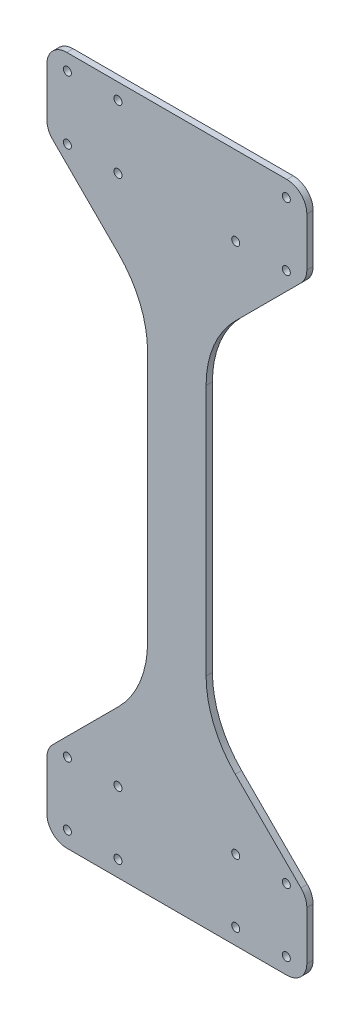
from build123d import *

# Parameters (mm, degrees)
BOSS_EXTRUDE1_DEPTH = 3.175
CUT_EXTRUDE1_DEPTH  = 10
SKETCH3_R           = 2.0193
BOSS_EXTRUDE2_DEPTH = 3.175
FILLET1_R           = 10
FILLET2_R           = 50


with BuildPart() as part:
    # Sketch1 → Boss-Extrude1 (new body)
    with BuildSketch(Plane.XY):
        Polygon((165.934536959, -16.66935), (157.315236959, -8.05005), (115.359952094, -8.05005), (89.959952094, -8.05005), (48.004667228, -8.05005), (39.385367228, -16.66935), (39.385367228, -40.05005), (39.385367228, -52.41105), (165.934536959, -56.67505), (165.934536959, -42.05005), align=None)
        with BuildLine():
            ThreePointArc((47.685367228, -44.38075), (49.704667228, -46.40005), (47.685367228, -48.41935))
            ThreePointArc((47.685367228, -48.41935), (45.666067228, -46.40005), (47.685367228, -44.38075))
        make_face(mode=Mode.SUBTRACT)
        with BuildLine():
            ThreePointArc((47.685367228, -12.63075), (49.704667228, -14.65005), (47.685367228, -16.66935))
            ThreePointArc((47.685367228, -16.66935), (45.666067228, -14.65005), (47.685367228, -12.63075))
        make_face(mode=Mode.SUBTRACT)
        with BuildLine():
            ThreePointArc((73.085367228, -44.38075), (75.104667228, -46.40005), (73.085367228, -48.41935))
            ThreePointArc((73.085367228, -48.41935), (71.066067228, -46.40005), (73.085367228, -44.38075))
        make_face(mode=Mode.SUBTRACT)
        with BuildLine():
            ThreePointArc((73.085367228, -12.63075), (75.104667228, -14.65005), (73.085367228, -16.66935))
            ThreePointArc((73.085367228, -16.66935), (71.066067228, -14.65005), (73.085367228, -12.63075))
        make_face(mode=Mode.SUBTRACT)
        with BuildLine():
            ThreePointArc((132.234536959, -44.38075), (134.253836959, -46.40005), (132.234536959, -48.41935))
            ThreePointArc((132.234536959, -48.41935), (130.215236959, -46.40005), (132.234536959, -44.38075))
        make_face(mode=Mode.SUBTRACT)
        with BuildLine():
            ThreePointArc((132.234536959, -12.63075), (134.253836959, -14.65005), (132.234536959, -16.66935))
            ThreePointArc((132.234536959, -16.66935), (130.215236959, -14.65005), (132.234536959, -12.63075))
        make_face(mode=Mode.SUBTRACT)
        with BuildLine():
            ThreePointArc((157.634536959, -44.38075), (159.653836959, -46.40005), (157.634536959, -48.41935))
            ThreePointArc((157.634536959, -48.41935), (155.615236959, -46.40005), (157.634536959, -44.38075))
        make_face(mode=Mode.SUBTRACT)
        with BuildLine():
            ThreePointArc((157.634536959, -12.63075), (159.653836959, -14.65005), (157.634536959, -16.66935))
            ThreePointArc((157.634536959, -16.66935), (155.615236959, -14.65005), (157.634536959, -12.63075))
        make_face(mode=Mode.SUBTRACT)
        Polygon((115.359952094, -8.05005), (157.315236959, -8.05005), (115.359952094, 33.905234866), align=None)
        Polygon((89.959952094, -8.05005), (115.359952094, -8.05005), (115.359952094, 33.905234866), (115.359952094, 203.394265134), (115.359952094, 245.34955), (89.959952094, 245.34955), (89.959952094, 203.394265134), (89.959952094, 33.905234866), align=None)
        Polygon((48.004667228, -8.05005), (89.959952094, -8.05005), (89.959952094, 33.905234866), align=None)
        Polygon((89.959952094, 245.34955), (115.359952094, 245.34955), (157.315236959, 245.34955), (165.934536959, 253.96885), (165.934536959, 279.34955), (165.934536959, 293.97455), (39.385367228, 289.71055), (39.385367228, 277.34955), (39.385367228, 253.96885), (48.004667228, 245.34955), align=None)
        with BuildLine():
            ThreePointArc((47.685367228, 253.96885), (49.704667228, 251.94955), (47.685367228, 249.93025))
            ThreePointArc((47.685367228, 249.93025), (45.666067228, 251.94955), (47.685367228, 253.96885))
        make_face(mode=Mode.SUBTRACT)
        with BuildLine():
            ThreePointArc((47.685367228, 285.71885), (49.704667228, 283.69955), (47.685367228, 281.68025))
            ThreePointArc((47.685367228, 281.68025), (45.666067228, 283.69955), (47.685367228, 285.71885))
        make_face(mode=Mode.SUBTRACT)
        with BuildLine():
            ThreePointArc((73.085367228, 253.96885), (75.104667228, 251.94955), (73.085367228, 249.93025))
            ThreePointArc((73.085367228, 249.93025), (71.066067228, 251.94955), (73.085367228, 253.96885))
        make_face(mode=Mode.SUBTRACT)
        with BuildLine():
            ThreePointArc((73.085367228, 285.71885), (75.104667228, 283.69955), (73.085367228, 281.68025))
            ThreePointArc((73.085367228, 281.68025), (71.066067228, 283.69955), (73.085367228, 285.71885))
        make_face(mode=Mode.SUBTRACT)
        with BuildLine():
            ThreePointArc((132.234536959, 253.96885), (134.253836959, 251.94955), (132.234536959, 249.93025))
            ThreePointArc((132.234536959, 249.93025), (130.215236959, 251.94955), (132.234536959, 253.96885))
        make_face(mode=Mode.SUBTRACT)
        with BuildLine():
            ThreePointArc((157.634536959, 253.96885), (159.653836959, 251.94955), (157.634536959, 249.93025))
            ThreePointArc((157.634536959, 249.93025), (155.615236959, 251.94955), (157.634536959, 253.96885))
        make_face(mode=Mode.SUBTRACT)
        with BuildLine():
            ThreePointArc((157.634536959, 285.71885), (159.653836959, 283.69955), (157.634536959, 281.68025))
            ThreePointArc((157.634536959, 281.68025), (155.615236959, 283.69955), (157.634536959, 285.71885))
        make_face(mode=Mode.SUBTRACT)
        Polygon((115.359952094, 245.34955), (115.359952094, 203.394265134), (157.315236959, 245.34955), align=None)
        Polygon((48.004667228, 245.34955), (89.959952094, 203.394265134), (89.959952094, 245.34955), align=None)
    extrude(amount=BOSS_EXTRUDE1_DEPTH)

    # Sketch2 → Cut-Extrude1 (cut)
    with BuildSketch(Plane.XY.offset(3.175)):
        Polygon((84.385367228, -52.41105), (39.385367228, -52.41105), (165.934536959, -56.67505), (165.934536959, -52.41105), (120.934536959, -52.41105), align=None)
        Polygon((120.934536959, 289.71055), (165.934536959, 289.71055), (165.934536959, 293.97455), (39.385367228, 289.71055), (84.385367228, 289.71055), align=None)
    extrude(amount=-CUT_EXTRUDE1_DEPTH, mode=Mode.SUBTRACT)

    # Sketch3 → Boss-Extrude2 (add)
    with BuildSketch(Plane.XY.offset(3.175)):
        Polygon((37.385367228, -15.840922875), (37.385367228, -54.41105), (167.934536959, -54.41105), (167.934536959, -15.840922875), (117.359952094, 34.73366199), (117.359952094, 202.56583801), (167.934536959, 253.140422875), (167.934536959, 291.71055), (37.385367228, 291.71055), (37.385367228, 253.140422875), (87.959952094, 202.56583801), (87.959952094, 34.73366199), align=None)
        with Locations((132.234536959, -46.40005)):
            Circle(SKETCH3_R, mode=Mode.SUBTRACT)
        with Locations((132.234536959, -14.65005)):
            Circle(SKETCH3_R, mode=Mode.SUBTRACT)
        with Locations((47.685367228, -14.65005)):
            Circle(SKETCH3_R, mode=Mode.SUBTRACT)
        with Locations((47.685367228, -46.40005)):
            Circle(SKETCH3_R, mode=Mode.SUBTRACT)
        with Locations((73.085367228, -46.40005)):
            Circle(SKETCH3_R, mode=Mode.SUBTRACT)
        with Locations((73.085367228, -14.65005)):
            Circle(SKETCH3_R, mode=Mode.SUBTRACT)
        with Locations((157.634536959, -14.65005)):
            Circle(SKETCH3_R, mode=Mode.SUBTRACT)
        with Locations((157.634536959, -46.40005)):
            Circle(SKETCH3_R, mode=Mode.SUBTRACT)
        with Locations((132.234536959, 251.94955)):
            Circle(SKETCH3_R, mode=Mode.SUBTRACT)
        with Locations((73.085367228, 251.94955)):
            Circle(SKETCH3_R, mode=Mode.SUBTRACT)
        with Locations((157.634536959, 251.94955)):
            Circle(SKETCH3_R, mode=Mode.SUBTRACT)
        with Locations((47.685367228, 251.94955)):
            Circle(SKETCH3_R, mode=Mode.SUBTRACT)
        with Locations((47.685367228, 283.69955)):
            Circle(SKETCH3_R, mode=Mode.SUBTRACT)
        with Locations((73.085367228, 283.69955)):
            Circle(SKETCH3_R, mode=Mode.SUBTRACT)
        with Locations((157.634536959, 283.69955)):
            Circle(SKETCH3_R, mode=Mode.SUBTRACT)
    extrude(amount=-BOSS_EXTRUDE2_DEPTH)

    # Fillet1
    fillet1_edges = [part.edges().sort_by_distance(p)[0] for p in [
        (37.385367228, -54.41105, 1.5875),
        (167.934536959, -54.41105, 1.5875),
        (167.934536959, -15.840922875, 1.5875),
        (167.934536959, 253.140422875, 1.5875),
        (167.934536959, 291.71055, 1.5875),
        (37.385367228, 291.71055, 1.5875),
        (37.385367228, 253.140422875, 1.5875),
        (37.385367228, -15.840922875, 1.5875),
    ]]
    fillet(fillet1_edges, radius=FILLET1_R)

    # Fillet2
    fillet2_edges = [part.edges().sort_by_distance(p)[0] for p in [
        (117.359952094, 34.73366199, 1.5875),
        (117.359952094, 202.56583801, 1.5875),
        (87.959952094, 202.56583801, 1.5875),
        (87.959952094, 34.73366199, 1.5875),
    ]]
    fillet(fillet2_edges, radius=FILLET2_R)


solid = part.part
